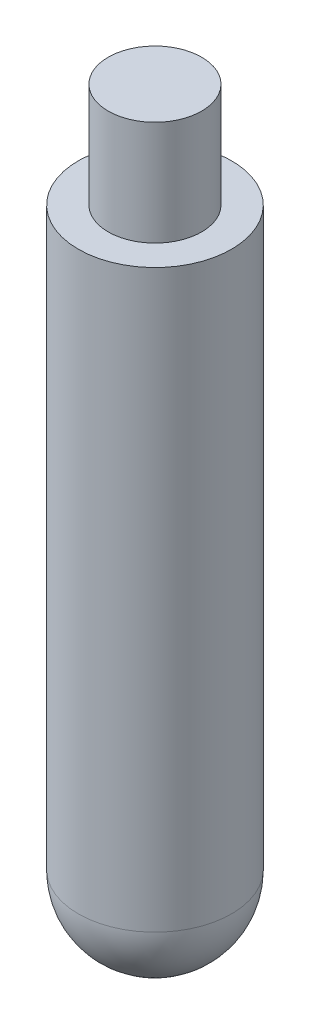
from build123d import *

# Parameters (mm, degrees)
CROQUIS1_R              = 2.05
SALIENTE_EXTRUIR1_DEPTH = 15.4
CROQUIS2_R              = 1.25
SALIENTE_EXTRUIR2_DEPTH = 2.8


with BuildPart() as part:
    # Croquis1 → Saliente-Extruir1 (new body)
    with BuildSketch(Plane(origin=(0, 0, 0), x_dir=(1, 0, 0), z_dir=(0, 1, 0))):
        Circle(CROQUIS1_R)
    extrude(amount=SALIENTE_EXTRUIR1_DEPTH)

    # Croquis2 → Saliente-Extruir2 (add)
    with BuildSketch(Plane(origin=(0, 15.4, 0), x_dir=(1, 0, 0), z_dir=(0, 1, 0))):
        Circle(CROQUIS2_R)
    extrude(amount=SALIENTE_EXTRUIR2_DEPTH)

    # Croquis4 → Revolución2 (revolve)
    with BuildSketch(Plane.XZ):
        with BuildLine():
            Line((0, -2.05), (0, 2.05))
            ThreePointArc((0, 2.05), (2.05, 0), (0, -2.05))
        make_face()
    revolve(axis=Axis((0, 0, -2.05), (0, 0, 1)))


solid = part.part
